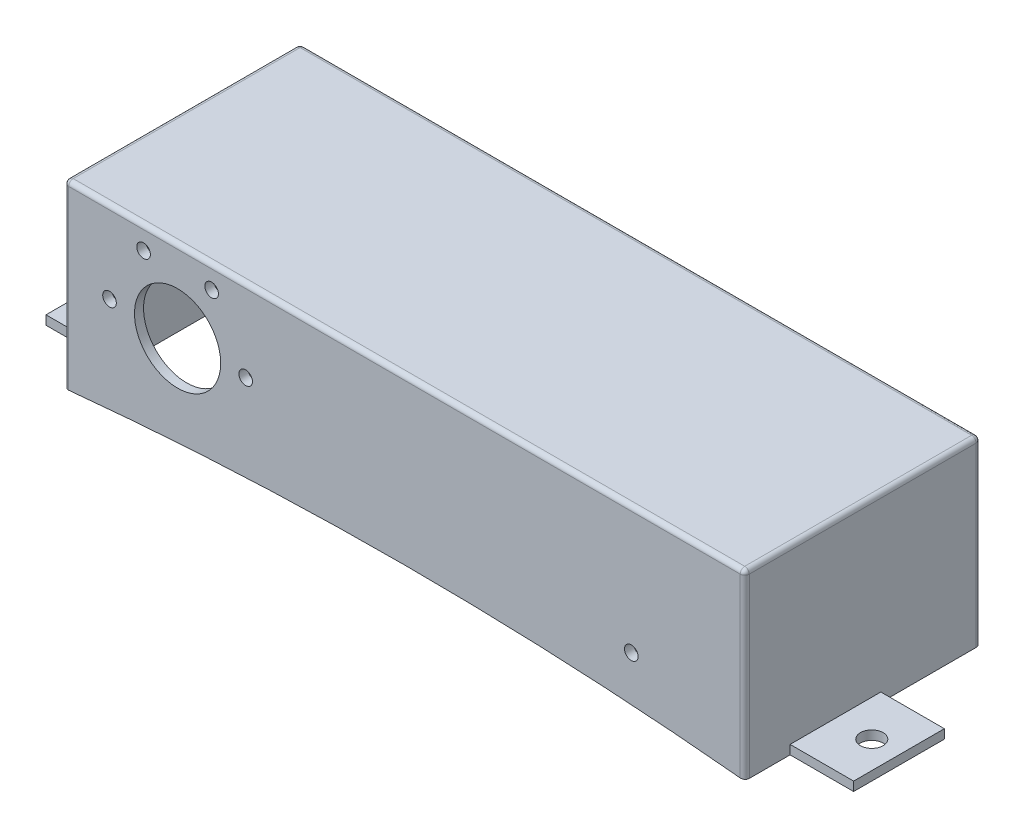
from build123d import *

# Parameters (mm, degrees)
SKETCH1_W           = 150
SKETCH1_H           = 40
SKETCH1_R           = 9.5
SKETCH1_R_2         = 1.5
BOSS_EXTRUDE1_DEPTH = 2
SKETCH2_W           = 150
SKETCH2_H           = 40
SKETCH2_W_2         = 146
SKETCH2_H_2         = 36
BOSS_EXTRUDE3_DEPTH = 50
CUT_EXTRUDE1_REACH  = 152
SKETCH4_R           = 5
SKETCH8_W           = 146
SKETCH8_H           = 2
CUT_EXTRUDE4_DEPTH  = 48
SKETCH9_W           = 150
SKETCH9_H           = 2
BOSS_EXTRUDE4_DEPTH = 40
SKETCH10_W          = 14
SKETCH10_H          = 2
BOSS_EXTRUDE5_DEPTH = 10
SKETCH11_R          = 2.5
CUT_EXTRUDE5_DEPTH  = 41
SKETCH12_R          = 1.5
SKETCH12_R_2        = 4
CUT_EXTRUDE6_DEPTH  = 2
CUT_EXTRUDE7_DEPTH  = 60
FILLET1_R           = 1


with BuildPart() as part:
    # Sketch1 → Boss-Extrude1 (new body)
    with BuildSketch(Plane.XY):
        Rectangle(SKETCH1_W, SKETCH1_H)
        with Locations((-50, 2)):
            Circle(SKETCH1_R, mode=Mode.SUBTRACT)
        with Locations((-65, 2)):
            Circle(SKETCH1_R_2, mode=Mode.SUBTRACT)
        with Locations((-57.5, 14.990381057)):
            Circle(SKETCH1_R_2, mode=Mode.SUBTRACT)
        with Locations((-42.5, 14.990381057)):
            Circle(SKETCH1_R_2, mode=Mode.SUBTRACT)
        with Locations((-35, 2)):
            Circle(SKETCH1_R_2, mode=Mode.SUBTRACT)
        with Locations((50, -8)):
            Circle(SKETCH1_R_2, mode=Mode.SUBTRACT)
    extrude(amount=BOSS_EXTRUDE1_DEPTH)

    # Sketch2 → Boss-Extrude3 (add)
    with BuildSketch(Plane.XY.offset(2)):
        Rectangle(SKETCH2_W, SKETCH2_H)
        Rectangle(SKETCH2_W_2, SKETCH2_H_2, mode=Mode.SUBTRACT)
    extrude(amount=-BOSS_EXTRUDE3_DEPTH)

    # Sketch4 → Cut-Extrude1 (cut, up to next)
    with BuildSketch(Plane.ZY.offset(75), mode=Mode.PRIVATE) as cut_extrude1_sk1:
        with Locations((-38, -2)):
            Circle(SKETCH4_R)
    cut_extrude1_tool1 = extrude(cut_extrude1_sk1.sketch, amount=-CUT_EXTRUDE1_REACH, mode=Mode.PRIVATE) & part.part
    add(cut_extrude1_tool1.solids().sort_by_distance((-75, -2, -38))[0], mode=Mode.SUBTRACT)

    # Sketch8 → Cut-Extrude4 (cut)
    with BuildSketch(Plane(origin=(0, 0, -48), x_dir=(-1, 0, 0), z_dir=(0, 0, -1))):
        with Locations((0, -19)):
            Rectangle(SKETCH8_W, SKETCH8_H)
    extrude(amount=-CUT_EXTRUDE4_DEPTH, mode=Mode.SUBTRACT)

    # Sketch9 → Boss-Extrude4 (add)
    with BuildSketch(Plane(origin=(0, 20, 0), x_dir=(1, 0, 0), z_dir=(0, 1, 0))):
        with Locations((0, 49)):
            Rectangle(SKETCH9_W, SKETCH9_H)
    extrude(amount=-BOSS_EXTRUDE4_DEPTH)

    # Sketch10 → Boss-Extrude5 (add, symmetric)
    with BuildSketch(Plane.XY.offset(-18)):
        with Locations((-82, -19)):
            Rectangle(SKETCH10_W, SKETCH10_H)
        with Locations((82, -19)):
            Rectangle(SKETCH10_W, SKETCH10_H)
    extrude(amount=BOSS_EXTRUDE5_DEPTH, both=True)

    # Sketch11 → Cut-Extrude5 (cut, through all)
    with BuildSketch(Plane(origin=(0, 20, 0), x_dir=(1, 0, 0), z_dir=(0, 1, 0))):
        with Locations((-83, 18)):
            Circle(SKETCH11_R)
        with Locations((83, 18)):
            Circle(SKETCH11_R)
    extrude(amount=-CUT_EXTRUDE5_DEPTH, mode=Mode.SUBTRACT)

    # Sketch12 → Cut-Extrude6 (cut)
    with BuildSketch(Plane(origin=(0, 0, -50), x_dir=(-1, 0, 0), z_dir=(0, 0, -1))):
        with Locations((-65.004612411, -6)):
            Circle(SKETCH12_R)
        with Locations((-40, -6)):
            Circle(SKETCH12_R)
        with Locations((-5, -6)):
            Circle(SKETCH12_R)
        with Locations((-30.004612411, -6)):
            Circle(SKETCH12_R)
        with Locations((5, -6)):
            Circle(SKETCH12_R_2)
        with BuildLine():
            Line((-59.85474671, -0.512445776), (-45.1498657, -0.512445776))
            ThreePointArc((-45.1498657, -0.512445776), (-43.670729064, -1.166282781), (-43.158706695, -2.700290966))
            Line((-43.158706695, -2.700290966), (-43.781293305, -9.299709034))
            ThreePointArc((-43.781293305, -9.299709034), (-44.426289315, -10.591000482), (-45.772452311, -11.111863845))
            Line((-45.772452311, -11.111863845), (-59.2321601, -11.111863845))
            ThreePointArc((-59.2321601, -11.111863845), (-60.578323096, -10.591000482), (-61.223319106, -9.299709034))
            Line((-61.223319106, -9.299709034), (-61.845905716, -2.700290966))
            ThreePointArc((-61.845905716, -2.700290966), (-61.333883347, -1.166282781), (-59.85474671, -0.512445776))
        make_face()
        with BuildLine():
            Line((-26.845905716, -2.700290966), (-26.223319106, -9.299709034))
            ThreePointArc((-26.223319106, -9.299709034), (-25.578323096, -10.591000482), (-24.2321601, -11.111863845))
            Line((-24.2321601, -11.111863845), (-10.772452311, -11.111863845))
            ThreePointArc((-10.772452311, -11.111863845), (-9.426289315, -10.591000482), (-8.781293305, -9.299709034))
            Line((-8.781293305, -9.299709034), (-8.158706695, -2.700290966))
            ThreePointArc((-8.158706695, -2.700290966), (-8.670729064, -1.166282781), (-10.1498657, -0.512445776))
            Line((-10.1498657, -0.512445776), (-24.85474671, -0.512445776))
            ThreePointArc((-24.85474671, -0.512445776), (-26.333883347, -1.166282781), (-26.845905716, -2.700290966))
        make_face()
    extrude(amount=-CUT_EXTRUDE6_DEPTH, mode=Mode.SUBTRACT)

    # Sketch14 → Cut-Extrude7 (cut)
    with BuildSketch(Plane(origin=(0, 0, -50), x_dir=(-1, 0, 0), z_dir=(0, 0, -1))):
        with BuildLine():
            Line((-75, -20), (75, -20))
            ThreePointArc((75, -20), (0, -16.24057783), (-75, -20))
        make_face()
    extrude(amount=-CUT_EXTRUDE7_DEPTH, mode=Mode.SUBTRACT)

    # Fillet1
    fillet1_edges = [part.edges().sort_by_distance(p)[0] for p in [
        (-75, 0, -50),
        (75, 0, -50),
        (0, 20, -50),
        (-75, 0, 2),
        (75, 0, 2),
        (-75, 20, -24),
        (75, 20, -24),
        (0, 20, 2),
    ]]
    fillet(fillet1_edges, radius=FILLET1_R)


solid = part.part
